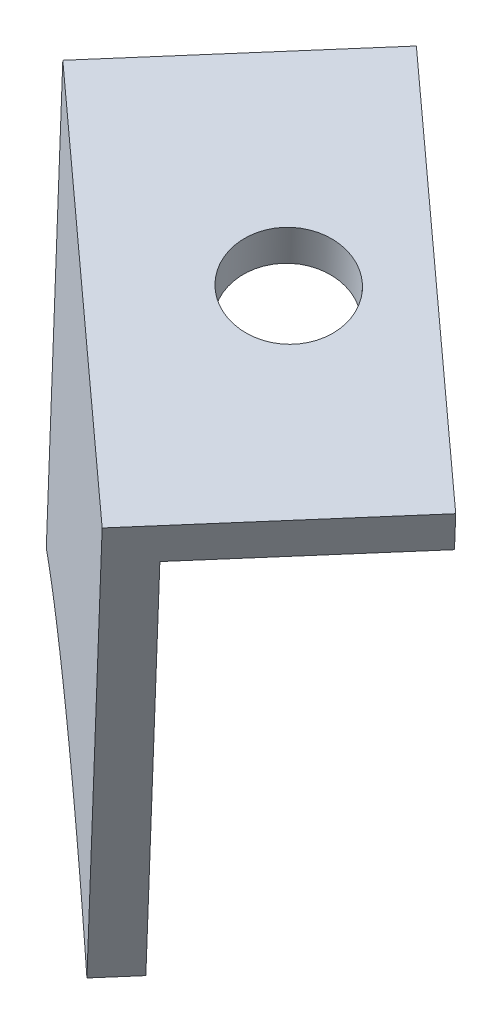
from build123d import *

# Parameters (mm, degrees)
DODANIE_WYCI_GNI_CIE1_DEPTH       = 2
WYCI_GNI_CIE_CIENKA_CIANKA1_DEPTH = 10
SZKIC3_R                          = 2.5
WYTNIJ_WYCI_GNI_CIE1_DEPTH        = 6


with BuildPart() as part:
    # Szkic1 → Dodanie-wyciągnięcie1 (new body)
    with BuildSketch(Plane(origin=(184.050171811, 0, -211.725502995), x_dir=(-0.75470958, 0, -0.656059029), z_dir=(0.656059029, 0, -0.75470958))):
        with BuildLine():
            Line((-818.756651821, -341.547090535), (-826.154339771, -317.666675693))
            Line((-826.154339771, -317.666675693), (-807.050007897, -311.748525334))
            Line((-807.050007897, -311.748525334), (-799.03222594, -337.630660478))
            add(Edge.make_bspline(
                [(-818.756651821, -341.547090535), (-812.651532186, -337.74352209), (-805.362739321, -336.365866813), (-799.03222594, -337.630660478)],
                knots=[0.197302397, 0.197302397, 0.197302397, 0.197302397, 0.33815529, 0.33815529, 0.33815529, 0.33815529], degree=3, weights=[0.522216299, 0.482629046, 0.495947227, 0.562170841]))
        make_face()
    extrude(amount=DODANIE_WYCI_GNI_CIE1_DEPTH)

    # Szkic2 → Wyciągnięcie-cienka ścianka1 (add)
    with BuildSketch(Plane(origin=(185.362289869, 0, -213.234922155), x_dir=(-0.75470958, 0, -0.656059029), z_dir=(0.656059029, 0, -0.75470958))):
        Polygon((-826.154339771, -317.666675693), (-807.050007897, -311.748525334), (-806.458192861, -313.658958521), (-825.562524735, -319.577108881), align=None)
    extrude(amount=WYCI_GNI_CIE_CIENKA_CIANKA1_DEPTH)

    # Szkic3 → Wytnij-wyciągnięcie1 (cut)
    with BuildSketch(Plane(origin=(-13.617240057, -58.24452258, -11.837286187), x_dir=(-0.974744215, 0.218850254, 0.044477883), z_dir=(-0.223324239, -0.955216594, -0.194132799))):
        with Locations((-839.308044037, -375.023490092)):
            Circle(SZKIC3_R)
    extrude(amount=-WYTNIJ_WYCI_GNI_CIE1_DEPTH, mode=Mode.SUBTRACT)


solid = part.part
